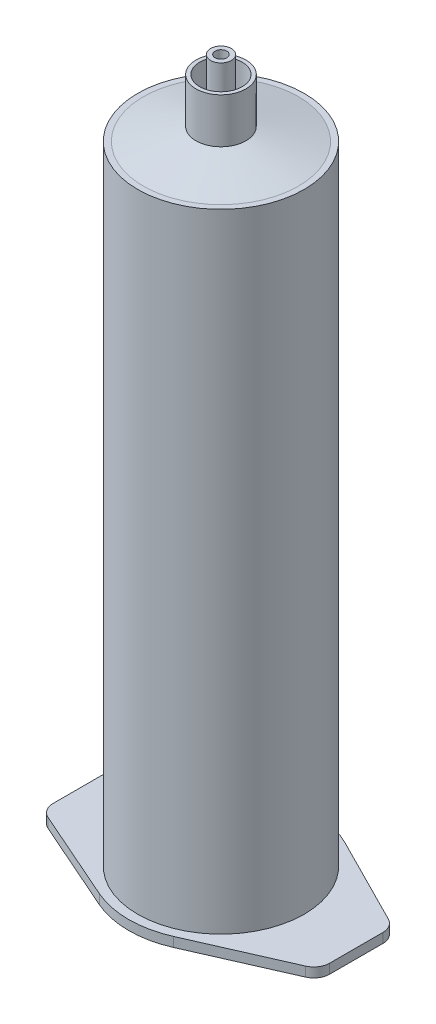
from build123d import *

# Parameters (mm, degrees)
SKETCH1_R                       = 15.65
SKETCH1_R_2                     = 14.575
BOSS_EXTRUDE1_DEPTH             = 118
BOSS_EXTRUDE2_DEPTH             = 1.8
BOSS_EXTRUDE3_REACH             = 136.386
SKETCH5_R                       = 4.7
SKETCH5_R_2                     = 4
SKETCH6_R                       = 1.95
SKETCH6_R_2                     = 1.1
BOSS_EXTRUDE4_DEPTH             = 3.25
BOSS_EXTRUDE4_DIRECTION_2_REACH = 136.386
SKETCH6_2_R                     = 1.1
CUT_EXTRUDE1_DEPTH              = 135.385685622


with BuildPart() as part:
    # Sketch1 → Boss-Extrude1 (new body)
    with BuildSketch(Plane(origin=(0, 0, 0), x_dir=(1, 0, 0), z_dir=(0, 1, 0))):
        with Locations(Location((0, 0, 0), (0, 0, 270))):
            Circle(SKETCH1_R)
        with Locations(Location((0, 0, 0), (0, 0, 270))):
            Circle(SKETCH1_R_2, mode=Mode.SUBTRACT)
    extrude(amount=BOSS_EXTRUDE1_DEPTH)

    # Sketch3 → Revolve1 (revolve)
    with BuildSketch(Plane.XY, mode=Mode.PRIVATE) as revolve1_sk:
        Polygon((-14.575, 118), (0, 121.6), (0, 120.52), (-14.575, 116.92), align=None)
    revolve(revolve1_sk.sketch.rotate(Axis((0, 0, 0), (0, 1, 0)), 270), axis=Axis((0, 0, 0), (0, 1, 0)))

    # Boss-Extrude3: up to this cone (the profile starts outside it)
    boss_extrude3_end = Plane(origin=(0, 128.9, 0), z_dir=(0, -1, 0)).offset(7.300001) * Cone(4.049e-06, 524.643319444, 129.585999, align=(Align.CENTER, Align.CENTER, Align.MIN), mode=Mode.PRIVATE)
    # Sketch5 → Boss-Extrude3 (add, up to the surface)
    with BuildSketch(Plane(origin=(0, 128.9, 0), x_dir=(-1, 0, 0), z_dir=(0, -1, 0)), mode=Mode.PRIVATE) as boss_extrude3_sk1:
        with Locations(Location((0, 0, 0), (0, 0, 90))):
            Circle(SKETCH5_R)
        with Locations(Location((0, 0, 0), (0, 0, 90))):
            Circle(SKETCH5_R_2, mode=Mode.SUBTRACT)
    boss_extrude3_tool1 = extrude(boss_extrude3_sk1.sketch, amount=BOSS_EXTRUDE3_REACH, mode=Mode.PRIVATE) - boss_extrude3_end
    add(boss_extrude3_tool1.solids().sort_by_distance((0, 128.9, 4.567064))[0])

    # Sketch6 → Boss-Extrude4 (add)
    with BuildSketch(Plane(origin=(0, 128.9, 0), x_dir=(1, 0, 0), z_dir=(0, 1, 0))):
        with Locations(Location((0, 0, 0), (0, 0, 270))):
            Circle(SKETCH6_R)
        with Locations(Location((0, 0, 0), (0, 0, 270))):
            Circle(SKETCH6_R_2, mode=Mode.SUBTRACT)
    extrude(amount=BOSS_EXTRUDE4_DEPTH)

    # Sketch6 → Boss-Extrude4 direction 2 (add, up to next)
    with BuildSketch(Plane(origin=(0, 128.9, 0), x_dir=(1, 0, 0), z_dir=(0, 1, 0)), mode=Mode.PRIVATE) as boss_extrude4_direction_2_sk1:
        with Locations(Location((0, 0, 0), (0, 0, 270))):
            Circle(SKETCH6_R)
        with Locations(Location((0, 0, 0), (0, 0, 270))):
            Circle(SKETCH6_R_2, mode=Mode.SUBTRACT)
    boss_extrude4_direction_2_tool1 = extrude(boss_extrude4_direction_2_sk1.sketch, amount=-BOSS_EXTRUDE4_DIRECTION_2_REACH, mode=Mode.PRIVATE) - part.part
    add(boss_extrude4_direction_2_tool1.solids().sort_by_distance((0, 128.9, -1.894846))[0])

    # Sketch6_2 → Cut-Extrude1 (cut, through all)
    with BuildSketch(Plane(origin=(0, 128.9, 0), x_dir=(1, 0, 0), z_dir=(0, 1, 0))):
        with Locations(Location((0, 0, 0), (0, 0, 270))):
            Circle(SKETCH6_2_R)
    extrude(amount=-CUT_EXTRUDE1_DEPTH, mode=Mode.SUBTRACT)


with BuildPart() as body_2:
    # Sketch2 → Boss-Extrude2 (new body)
    with BuildSketch(Plane.XZ):
        with BuildLine():
            ThreePointArc((-7.832015244, -15.481667779), (-17.343773926, 0.464764477), (-6.991640016, 15.878900147))
            Line((-6.991640016, 15.878900147), (-24.208929109, 8.297953968))
            ThreePointArc((-24.208929109, 8.297953968), (-25.512646745, 7.191409862), (-26, 5.552322819))
            Line((-26, 5.552322819), (-26, -4.446300643))
            ThreePointArc((-26, -4.446300643), (-25.55565225, -6.017491777), (-24.354238947, -7.12324608))
            Line((-24.354238947, -7.12324608), (-7.832015244, -15.481667779))
        make_face()
        with BuildLine():
            ThreePointArc((17.35, 0), (14.531473674, 9.479386734), (6.991640016, 15.878900147))
            ThreePointArc((6.991640016, 15.878900147), (3.572364934, 16.978242217), (0, 17.35))
            Line((0, 17.35), (0, 15.65))
            ThreePointArc((0, 15.65), (11.066221126, 11.066221126), (15.65, 0))
            ThreePointArc((15.65, 0), (11.066221126, -11.066221126), (0, -15.65))
            Line((0, -15.65), (0, -17.35))
            ThreePointArc((0, -17.35), (4.025888972, -16.876454544), (7.832015244, -15.481667779))
            ThreePointArc((7.832015244, -15.481667779), (14.780188843, -9.086722058), (17.35, 0))
        make_face()
        with BuildLine():
            Line((0, 15.65), (0, 17.35))
            ThreePointArc((0, 17.35), (-3.572364934, 16.978242217), (-6.991640016, 15.878900147))
            ThreePointArc((-6.991640016, 15.878900147), (-17.343773926, 0.464764477), (-7.832015244, -15.481667779))
            ThreePointArc((-7.832015244, -15.481667779), (-4.025888972, -16.876454544), (0, -17.35))
            Line((0, -17.35), (0, -15.65))
            ThreePointArc((0, -15.65), (-15.65, 0), (0, 15.65))
        make_face()
        with BuildLine():
            ThreePointArc((17.35, 0), (14.531473674, 9.479386734), (6.991640016, 15.878900147))
            ThreePointArc((6.991640016, 15.878900147), (3.572364934, 16.978242217), (0, 17.35))
            Line((0, 17.35), (0, 15.65))
            ThreePointArc((0, 15.65), (11.066221126, 11.066221126), (15.65, 0))
            ThreePointArc((15.65, 0), (11.066221126, -11.066221126), (0, -15.65))
            Line((0, -15.65), (0, -17.35))
            ThreePointArc((0, -17.35), (4.025888972, -16.876454544), (7.832015244, -15.481667779))
            ThreePointArc((7.832015244, -15.481667779), (14.780188843, -9.086722058), (17.35, 0))
        make_face()
        with BuildLine():
            Line((0, 15.65), (0, 17.35))
            ThreePointArc((0, 17.35), (-3.572364934, 16.978242217), (-6.991640016, 15.878900147))
            ThreePointArc((-6.991640016, 15.878900147), (-17.343773926, 0.464764477), (-7.832015244, -15.481667779))
            ThreePointArc((-7.832015244, -15.481667779), (-4.025888972, -16.876454544), (0, -17.35))
            Line((0, -17.35), (0, -15.65))
            ThreePointArc((0, -15.65), (-15.65, 0), (0, 15.65))
        make_face()
        with BuildLine():
            Line((26, -4.446300643), (26, 5.552322819))
            ThreePointArc((26, 5.552322819), (25.512646745, 7.191409862), (24.208929109, 8.297953968))
            Line((24.208929109, 8.297953968), (6.991640016, 15.878900147))
            ThreePointArc((6.991640016, 15.878900147), (14.531473674, 9.479386734), (17.35, 0))
            ThreePointArc((17.35, 0), (14.780188843, -9.086722058), (7.832015244, -15.481667779))
            Line((7.832015244, -15.481667779), (24.354238947, -7.12324608))
            ThreePointArc((24.354238947, -7.12324608), (25.55565225, -6.017491777), (26, -4.446300643))
        make_face()
        with BuildLine():
            ThreePointArc((15.65, 0), (11.066221126, 11.066221126), (0, 15.65))
            Line((0, 15.65), (0, 14.575))
            ThreePointArc((0, 14.575), (10.306081336, 10.306081336), (14.575, 0))
            ThreePointArc((14.575, 0), (10.306081336, -10.306081336), (0, -14.575))
            Line((0, -14.575), (0, -15.65))
            ThreePointArc((0, -15.65), (11.066221126, -11.066221126), (15.65, 0))
        make_face()
        with BuildLine():
            Line((0, 14.575), (0, 15.65))
            ThreePointArc((0, 15.65), (-15.65, 0), (0, -15.65))
            Line((0, -15.65), (0, -14.575))
            ThreePointArc((0, -14.575), (-14.575, 0), (0, 14.575))
        make_face()
        with BuildLine():
            ThreePointArc((15.65, 0), (11.066221126, 11.066221126), (0, 15.65))
            Line((0, 15.65), (0, 14.575))
            ThreePointArc((0, 14.575), (10.306081336, 10.306081336), (14.575, 0))
            ThreePointArc((14.575, 0), (10.306081336, -10.306081336), (0, -14.575))
            Line((0, -14.575), (0, -15.65))
            ThreePointArc((0, -15.65), (11.066221126, -11.066221126), (15.65, 0))
        make_face()
        with BuildLine():
            Line((0, 14.575), (0, 15.65))
            ThreePointArc((0, 15.65), (-15.65, 0), (0, -15.65))
            Line((0, -15.65), (0, -14.575))
            ThreePointArc((0, -14.575), (-14.575, 0), (0, 14.575))
        make_face()
    extrude(amount=BOSS_EXTRUDE2_DEPTH)


solid = Compound([part.part, body_2.part])
